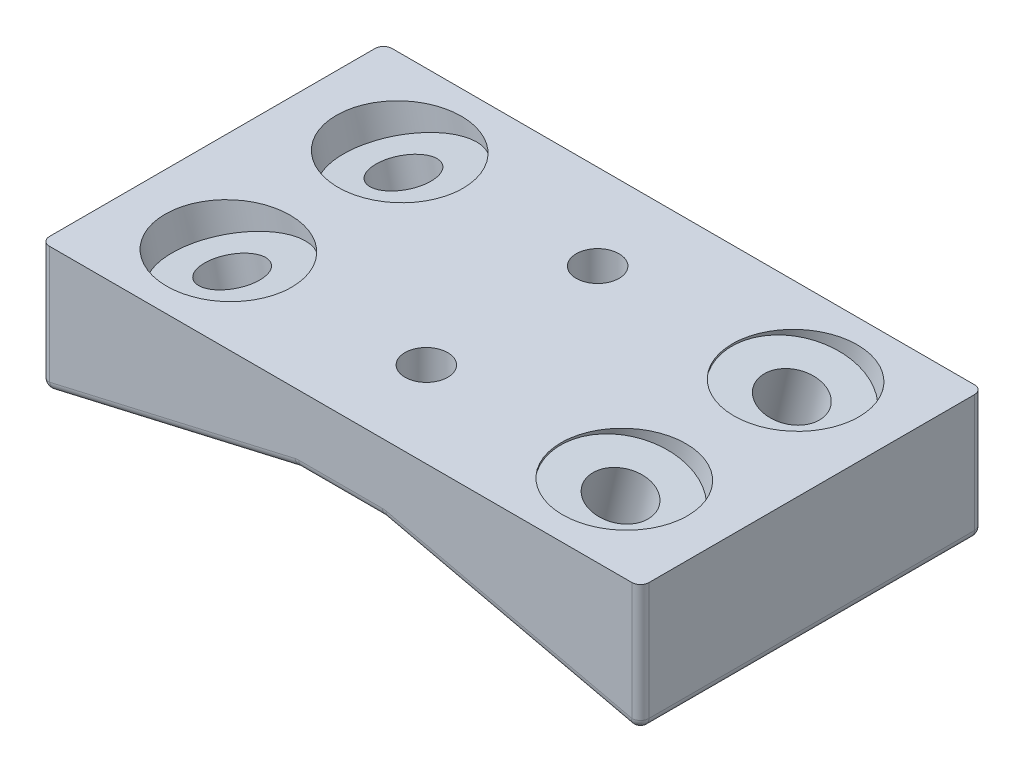
from build123d import *

# Parameters (mm, degrees)
BOSS_EXTRUDE1_DEPTH          = 40
F_5_0_5_DIAMETER_HOLE1_D     = 5
F_5_0_5_DIAMETER_HOLE1_DEPTH = 19
F_5_0_5_DIAMETER_HOLE1_TIP   = 1.502151548
FILLET1_R                    = 1
M6_CLEARANCE_HOLE3_D         = 6.6
M6_CLEARANCE_HOLE4_D         = 6.6
M6_CLEARANCE_HOLE4_DEPTH     = 19
M6_CLEARANCE_HOLE4_TIP       = 1.982840043
CUT_EXTRUDE2_START           = -10
SKETCH16_R                   = 7.2
CUT_EXTRUDE2_DEPTH           = 5.615550972
CUT_EXTRUDE3_START           = -10
SKETCH17_R                   = 7.2
CUT_EXTRUDE3_DEPTH           = 5.615550972


with BuildPart() as part:
    # Sketch1 → Boss-Extrude1 (new body)
    with BuildSketch(Plane.XY):
        Polygon((0, 0), (0, 15), (70, 15), (70, 0), (40, 6.926045734), (30, 6.926045734), align=None)
    extrude(amount=-BOSS_EXTRUDE1_DEPTH)

    # Ø5.0 (5) Diameter Hole1
    with Locations(Plane(origin=(0, 15, 0), x_dir=(1, 0, 0), z_dir=(0, 1, 0))):
        with Locations((35, 10), (35, 30)):
            Hole(F_5_0_5_DIAMETER_HOLE1_D / 2, depth=F_5_0_5_DIAMETER_HOLE1_DEPTH)
            with Locations((0, 0, -(F_5_0_5_DIAMETER_HOLE1_DEPTH + F_5_0_5_DIAMETER_HOLE1_TIP / 2))):  # 118° drill point
                Cone(0, F_5_0_5_DIAMETER_HOLE1_D / 2, F_5_0_5_DIAMETER_HOLE1_TIP, mode=Mode.SUBTRACT)

    # Fillet1
    fillet1_edges = [part.edges().sort_by_distance(p)[0] for p in [
        (55, 3.463022867, -40),
        (0, 0, -20),
        (70, 0, -20),
        (40, 6.926045734, -20),
        (30, 6.926045734, -20),
        (70, 7.5, -40),
        (0, 7.5, -40),
        (15, 3.463022867, -40),
        (0, 7.5, 0),
        (70, 7.5, 0),
        (35, 6.926045734, -40),
        (55, 3.463022867, 0),
        (35, 6.926045734, 0),
        (15, 3.463022867, 0),
    ]]
    fillet(fillet1_edges, radius=FILLET1_R)

    # M6 Clearance Hole3 (through all)
    with Locations(Plane(origin=(0, 0, 0), x_dir=(-0.974370065, -0.224951054, 0), z_dir=(0.224951054, -0.974370065, 0))):
        with Locations((-14.957172299, 10), (-14.957172299, 30)):
            Hole(M6_CLEARANCE_HOLE3_D / 2)

    # M6 Clearance Hole4
    with Locations(Plane(origin=(3.54220838, 15.342990138, 0), x_dir=(-0.974370065, 0.224951054, 0), z_dir=(-0.224951054, -0.974370065, 0))):
        with Locations((-53.248732236, 10), (-53.248732236, 30)):
            Hole(M6_CLEARANCE_HOLE4_D / 2, depth=M6_CLEARANCE_HOLE4_DEPTH)
            with Locations((0, 0, -(M6_CLEARANCE_HOLE4_DEPTH + M6_CLEARANCE_HOLE4_TIP / 2))):  # 118° drill point
                Cone(0, M6_CLEARANCE_HOLE4_D / 2, M6_CLEARANCE_HOLE4_TIP, mode=Mode.SUBTRACT)

    # Sketch16 → Cut-Extrude2 (cut, through all)
    with BuildSketch(Plane(origin=(0, 0, 0), x_dir=(0.974370065, 0.224951054, 0), z_dir=(0.224951054, -0.974370065, 0)).offset(CUT_EXTRUDE2_START)):
        with Locations((14.957172299, -10)):
            Circle(SKETCH16_R)
        with Locations((14.957172299, -30)):
            Circle(SKETCH16_R)
    extrude(amount=-CUT_EXTRUDE2_DEPTH, mode=Mode.SUBTRACT)

    # Sketch17 → Cut-Extrude3 (cut, through all)
    with BuildSketch(Plane(origin=(3.54220838, 15.342990138, 0), x_dir=(0.974370065, -0.224951054, 0), z_dir=(-0.224951054, -0.974370065, 0)).offset(CUT_EXTRUDE3_START)):
        with Locations((53.248732236, -10)):
            Circle(SKETCH17_R)
        with Locations((53.248732236, -30)):
            Circle(SKETCH17_R)
    extrude(amount=-CUT_EXTRUDE3_DEPTH, mode=Mode.SUBTRACT)


solid = part.part
